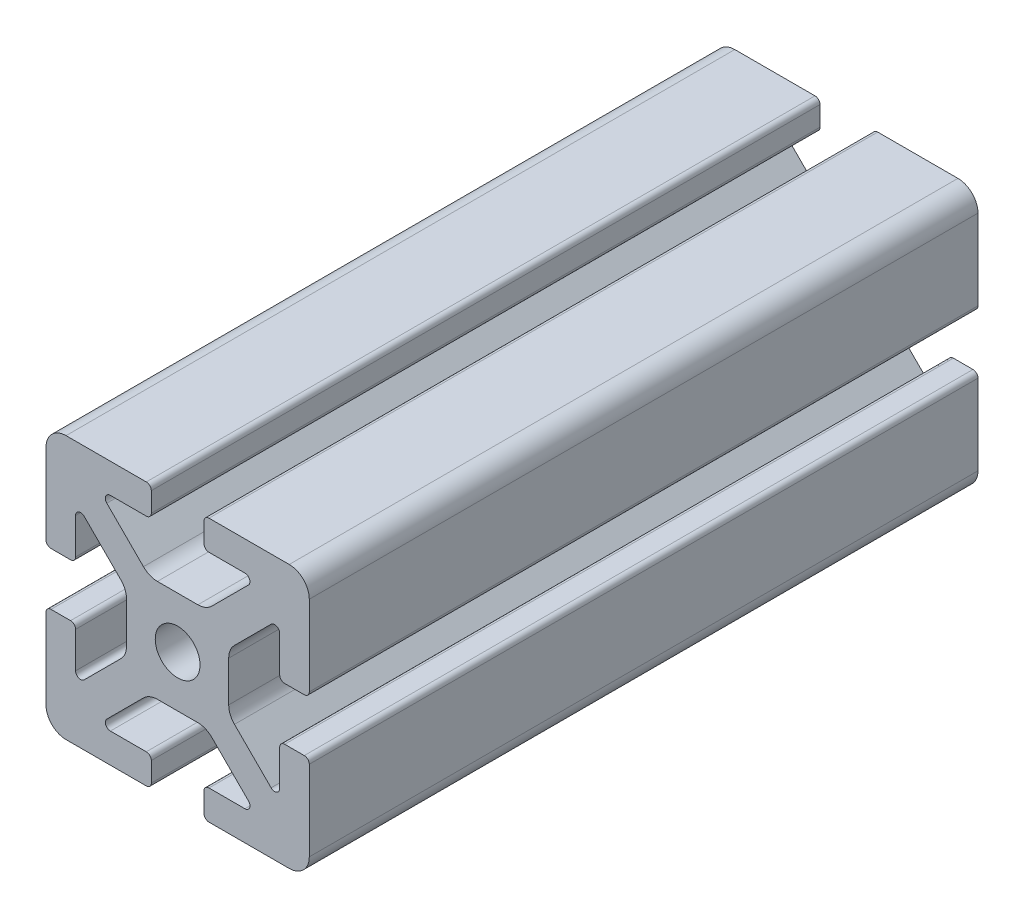
from build123d import *

# Parameters (mm, degrees)
SKETCH1_R               = 3.4036
BOSS_EXTRUDE1_DEPTH     = 380
SKETCH2_W               = 379
SKETCH2_H               = 40
CUT_EXTRUDE1_DEPTH      = 65
CUT_EXTRUDE1_DEPTH_BACK = 71
SKETCH4_W               = 279.4
SKETCH4_H               = 55.537742005
CUT_EXTRUDE2_DEPTH      = 30
CUT_EXTRUDE2_DEPTH_BACK = 30


with BuildPart() as part:
    # Sketch1 → Boss-Extrude1 (new body, symmetric)
    with BuildSketch(Plane.XY):
        with BuildLine():
            Line((-20, 16.952), (-20, 4.7625))
            ThreePointArc((-20, 4.7625), (-19.776815367, 4.223684633), (-19.238, 4.0005))
            Line((-19.238, 4.0005), (-16.2662, 4.0005))
            ThreePointArc((-16.2662, 4.0005), (-15.727384633, 4.223684633), (-15.5042, 4.7625))
            Line((-15.5042, 4.7625), (-15.5042, 10.2235))
            ThreePointArc((-15.5042, 10.2235), (-15.033804775, 10.927496204), (-14.203384633, 10.762315367))
            Line((-14.203384633, 10.762315367), (-8.635059555, 5.19399029))
            ThreePointArc((-8.635059555, 5.19399029), (-7.985348265, 4.221628629), (-7.7572, 3.074649845))
            Line((-7.7572, 3.074649845), (-7.7572, -3.074649845))
            ThreePointArc((-7.7572, -3.074649845), (-7.985348265, -4.221628629), (-8.635059555, -5.19399029))
            Line((-8.635059555, -5.19399029), (-14.203384633, -10.762315367))
            ThreePointArc((-14.203384633, -10.762315367), (-15.033804775, -10.927496204), (-15.5042, -10.2235))
            Line((-15.5042, -10.2235), (-15.5042, -4.7625))
            ThreePointArc((-15.5042, -4.7625), (-15.727384633, -4.223684633), (-16.2662, -4.0005))
            Line((-16.2662, -4.0005), (-19.238, -4.0005))
            ThreePointArc((-19.238, -4.0005), (-19.776815367, -4.223684633), (-20, -4.7625))
            Line((-20, -4.7625), (-20, -16.952))
            ThreePointArc((-20, -16.952), (-19.107261469, -19.107261469), (-16.952, -20))
            Line((-16.952, -20), (-4.7625, -20))
            ThreePointArc((-4.7625, -20), (-4.223684633, -19.776815367), (-4.0005, -19.238))
            Line((-4.0005, -19.238), (-4.0005, -16.2662))
            ThreePointArc((-4.0005, -16.2662), (-4.223684633, -15.727384633), (-4.7625, -15.5042))
            Line((-4.7625, -15.5042), (-10.2235, -15.5042))
            ThreePointArc((-10.2235, -15.5042), (-10.927496204, -15.033804775), (-10.762315367, -14.203384633))
            Line((-10.762315367, -14.203384633), (-5.19399029, -8.635059555))
            ThreePointArc((-5.19399029, -8.635059555), (-4.221628629, -7.985348265), (-3.074649845, -7.7572))
            Line((-3.074649845, -7.7572), (3.074649845, -7.7572))
            ThreePointArc((3.074649845, -7.7572), (4.221628629, -7.985348265), (5.19399029, -8.635059555))
            Line((5.19399029, -8.635059555), (10.762315367, -14.203384633))
            ThreePointArc((10.762315367, -14.203384633), (10.927496204, -15.033804775), (10.2235, -15.5042))
            Line((10.2235, -15.5042), (4.7625, -15.5042))
            ThreePointArc((4.7625, -15.5042), (4.223684633, -15.727384633), (4.0005, -16.2662))
            Line((4.0005, -16.2662), (4.0005, -19.238))
            ThreePointArc((4.0005, -19.238), (4.223684633, -19.776815367), (4.7625, -20))
            Line((4.7625, -20), (16.952, -20))
            ThreePointArc((16.952, -20), (19.107261469, -19.107261469), (20, -16.952))
            Line((20, -16.952), (20, -4.7625))
            ThreePointArc((20, -4.7625), (19.776815367, -4.223684633), (19.238, -4.0005))
            Line((19.238, -4.0005), (16.2662, -4.0005))
            ThreePointArc((16.2662, -4.0005), (15.727384633, -4.223684633), (15.5042, -4.7625))
            Line((15.5042, -4.7625), (15.5042, -10.2235))
            ThreePointArc((15.5042, -10.2235), (15.033804775, -10.927496204), (14.203384633, -10.762315367))
            Line((14.203384633, -10.762315367), (8.635059555, -5.19399029))
            ThreePointArc((8.635059555, -5.19399029), (7.985348265, -4.221628629), (7.7572, -3.074649845))
            Line((7.7572, -3.074649845), (7.7572, 3.074649845))
            ThreePointArc((7.7572, 3.074649845), (7.985348265, 4.221628629), (8.635059555, 5.19399029))
            Line((8.635059555, 5.19399029), (14.203384633, 10.762315367))
            ThreePointArc((14.203384633, 10.762315367), (15.033804775, 10.927496204), (15.5042, 10.2235))
            Line((15.5042, 10.2235), (15.5042, 4.7625))
            ThreePointArc((15.5042, 4.7625), (15.727384633, 4.223684633), (16.2662, 4.0005))
            Line((16.2662, 4.0005), (19.238, 4.0005))
            ThreePointArc((19.238, 4.0005), (19.776815367, 4.223684633), (20, 4.7625))
            Line((20, 4.7625), (20, 16.952))
            ThreePointArc((20, 16.952), (19.107261469, 19.107261469), (16.952, 20))
            Line((16.952, 20), (4.7625, 20))
            ThreePointArc((4.7625, 20), (4.223684633, 19.776815367), (4.0005, 19.238))
            Line((4.0005, 19.238), (4.0005, 16.2662))
            ThreePointArc((4.0005, 16.2662), (4.223684633, 15.727384633), (4.7625, 15.5042))
            Line((4.7625, 15.5042), (10.2235, 15.5042))
            ThreePointArc((10.2235, 15.5042), (10.927496204, 15.033804775), (10.762315367, 14.203384633))
            Line((10.762315367, 14.203384633), (5.19399029, 8.635059555))
            ThreePointArc((5.19399029, 8.635059555), (4.221628629, 7.985348265), (3.074649845, 7.7572))
            Line((3.074649845, 7.7572), (-3.074649845, 7.7572))
            ThreePointArc((-3.074649845, 7.7572), (-4.221628629, 7.985348265), (-5.19399029, 8.635059555))
            Line((-5.19399029, 8.635059555), (-10.762315367, 14.203384633))
            ThreePointArc((-10.762315367, 14.203384633), (-10.927496204, 15.033804775), (-10.2235, 15.5042))
            Line((-10.2235, 15.5042), (-4.7625, 15.5042))
            ThreePointArc((-4.7625, 15.5042), (-4.223684633, 15.727384633), (-4.0005, 16.2662))
            Line((-4.0005, 16.2662), (-4.0005, 19.238))
            ThreePointArc((-4.0005, 19.238), (-4.223684633, 19.776815367), (-4.7625, 20))
            Line((-4.7625, 20), (-16.952, 20))
            ThreePointArc((-16.952, 20), (-19.107261469, 19.107261469), (-20, 16.952))
        make_face()
        Circle(SKETCH1_R, mode=Mode.SUBTRACT)
    extrude(amount=BOSS_EXTRUDE1_DEPTH, both=True)

    # Sketch2 → Cut-Extrude1 (cut, two sides)
    with BuildSketch(Plane(origin=(0, 0, 0), x_dir=(0, 0, -1), z_dir=(1, 0, 0))) as cut_extrude1_sk:
        with Locations((190.5, 0)):
            Rectangle(SKETCH2_W, SKETCH2_H)
    extrude(amount=CUT_EXTRUDE1_DEPTH, mode=Mode.SUBTRACT)
    extrude(cut_extrude1_sk.sketch, amount=-CUT_EXTRUDE1_DEPTH_BACK, mode=Mode.SUBTRACT)

    # Sketch4 → Cut-Extrude2 (cut, two sides)
    with BuildSketch(Plane(origin=(0, 0, 0), x_dir=(0, 0, -1), z_dir=(1, 0, 0))) as cut_extrude2_sk:
        with Locations((-138.7, -7.768871003)):
            Rectangle(SKETCH4_W, SKETCH4_H)
    extrude(amount=CUT_EXTRUDE2_DEPTH, mode=Mode.SUBTRACT)
    extrude(cut_extrude2_sk.sketch, amount=-CUT_EXTRUDE2_DEPTH_BACK, mode=Mode.SUBTRACT)


solid = part.part
